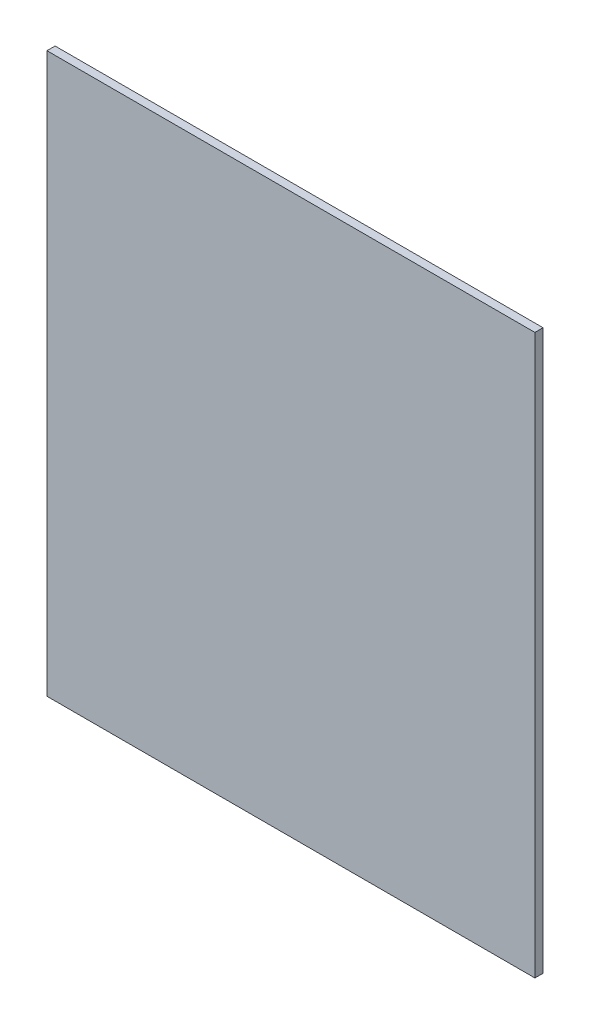
from build123d import *

# Parameters (mm, degrees)
SKETCH1_W           = 96
SKETCH1_H           = 110
BOSS_EXTRUDE1_DEPTH = 1.6


with BuildPart() as part:
    # Sketch1 → Boss-Extrude1 (new body)
    with BuildSketch(Plane.XY):
        Rectangle(SKETCH1_W, SKETCH1_H)
    extrude(amount=BOSS_EXTRUDE1_DEPTH)


solid = part.part
